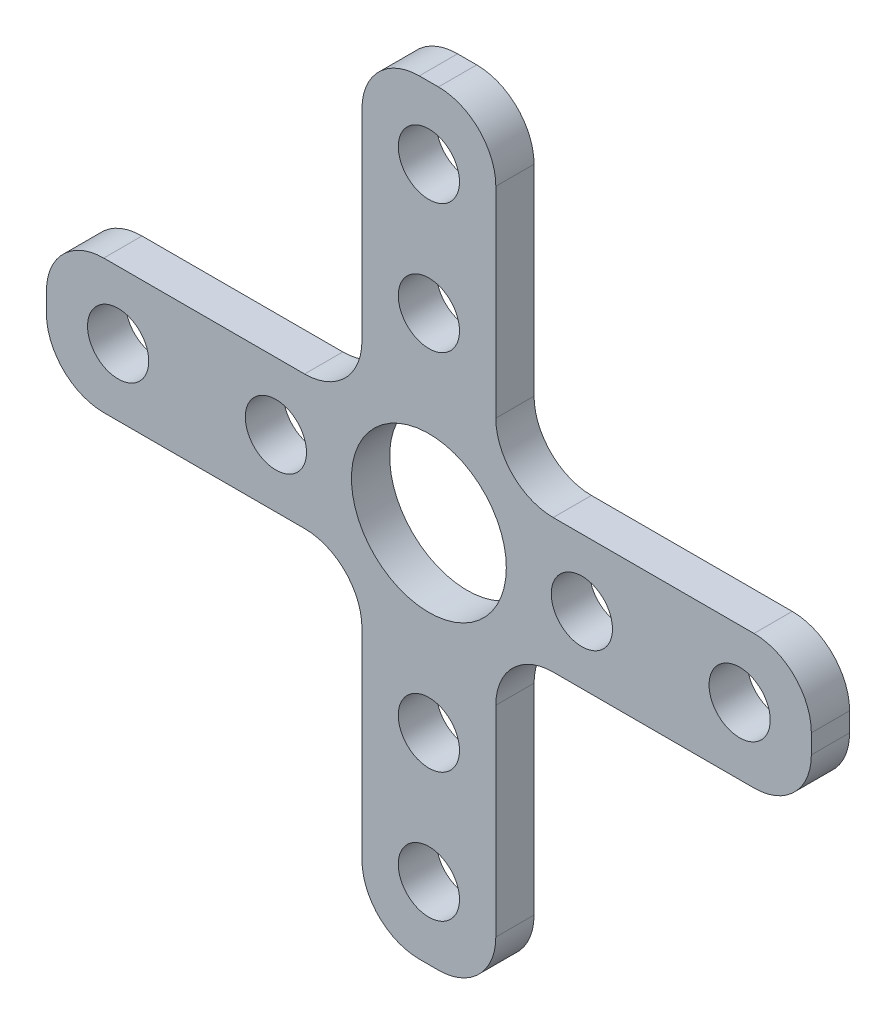
from build123d import *

# Parameters (mm, degrees)
CROQUIS1_R              = 1.6
CROQUIS1_R_2            = 4.05
SALIENTE_EXTRUIR1_DEPTH = 1
REDONDEO1_R             = 3


with BuildPart() as part:
    # Croquis1 → Saliente-Extruir1 (new body, symmetric)
    with BuildSketch(Plane.XY):
        Polygon((3.5, -3.5), (20, -3.5), (20, 3.5), (3.5, 3.5), (3.5, 20), (-3.5, 20), (-3.5, 3.5), (-20, 3.5), (-20, -3.5), (-3.5, -3.5), (-3.5, -20), (3.5, -20), align=None)
        with Locations((-8, 0)):
            Circle(CROQUIS1_R, mode=Mode.SUBTRACT)
        with Locations((8, 0)):
            Circle(CROQUIS1_R, mode=Mode.SUBTRACT)
        with Locations((0, 16.25)):
            Circle(CROQUIS1_R, mode=Mode.SUBTRACT)
        with Locations((0, -16.25)):
            Circle(CROQUIS1_R, mode=Mode.SUBTRACT)
        Circle(CROQUIS1_R_2, mode=Mode.SUBTRACT)
        with Locations((0, 9.5)):
            Circle(CROQUIS1_R, mode=Mode.SUBTRACT)
        with Locations((0, -9.5)):
            Circle(CROQUIS1_R, mode=Mode.SUBTRACT)
        with Locations((-16.25, 0)):
            Circle(CROQUIS1_R, mode=Mode.SUBTRACT)
        with Locations((16.25, 0)):
            Circle(CROQUIS1_R, mode=Mode.SUBTRACT)
    extrude(amount=SALIENTE_EXTRUIR1_DEPTH, both=True)

    # Redondeo1
    redondeo1_edges = [part.edges().sort_by_distance(p)[0] for p in [
        (3.5, -20, 0),
        (-3.5, -20, 0),
        (-3.5, -3.5, 0),
        (-20, -3.5, 0),
        (-20, 3.5, 0),
        (-3.5, 3.5, 0),
        (-3.5, 20, 0),
        (3.5, 20, 0),
        (3.5, 3.5, 0),
        (20, 3.5, 0),
        (20, -3.5, 0),
        (3.5, -3.5, 0),
    ]]
    fillet(redondeo1_edges, radius=REDONDEO1_R)


solid = part.part
